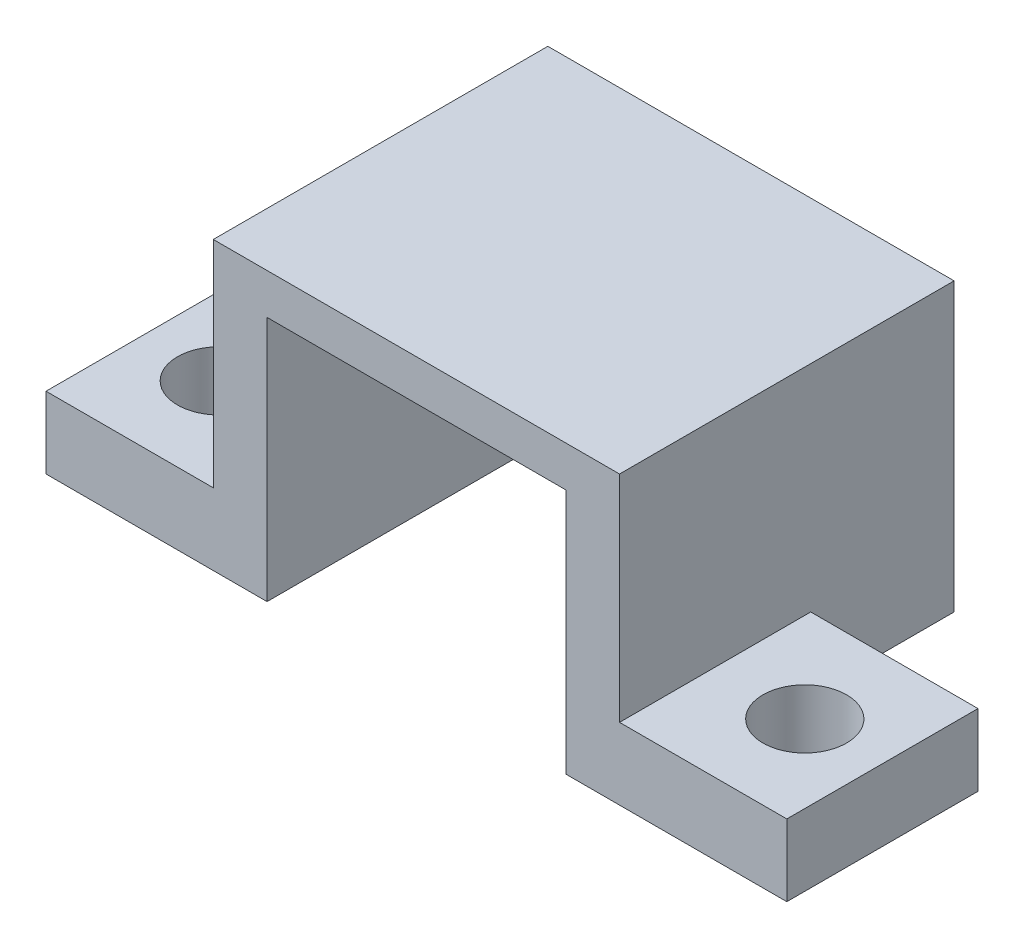
from build123d import *

# Parameters (mm, degrees)
ESBO_O1_W                = 17.000001856
ESBO_O1_H                = 13.999999967
RESSALTO_EXTRUS_O1_DEPTH = 12.000000396
ESBO_O2_W                = 12.500001117
ESBO_O2_H                = 10.30000049
CORTE_EXTRUS_O1_DEPTH    = 14.999999966
ESBO_O3_W                = 7.999999915
ESBO_O3_H                = 3.000000085
RESSALTO_EXTRUS_O2_DEPTH = 6.999999285
ESBO_O4_R                = 1.75
CORTE_EXTRUS_O2_DEPTH    = 13.000000396
ESBO_O5_W                = 7.999999915
ESBO_O5_H                = 3.000000085
RESSALTO_EXTRUS_O3_DEPTH = 6.999999285
ESBO_O6_R                = 1.75
CORTE_EXTRUS_O3_DEPTH    = 13.000000396


with BuildPart() as part:
    # Esboço1 → Ressalto-extrusão1 (new body)
    with BuildSketch(Plane.XZ.offset(-5e-05)):
        with Locations((15.500025358, 7.000024663)):
            Rectangle(ESBO_O1_W, ESBO_O1_H)
    extrude(amount=-RESSALTO_EXTRUS_O1_DEPTH)

    # Esboço2 → Corte-extrusão1 (cut, through all)
    with BuildSketch(Plane.XY.offset(14.000024647)):
        with Locations((15.500024893, 5.150050245)):
            Rectangle(ESBO_O2_W, ESBO_O2_H)
    extrude(amount=-CORTE_EXTRUS_O1_DEPTH, mode=Mode.SUBTRACT)

    # Esboço3 → Ressalto-extrusão2 (add)
    with BuildSketch(Plane.ZY.offset(-7.00002443)):
        with Locations((10.00002469, 1.500050043)):
            Rectangle(ESBO_O3_W, ESBO_O3_H)
    extrude(amount=RESSALTO_EXTRUS_O2_DEPTH)

    # Esboço4 → Corte-extrusão2 (cut, through all)
    with BuildSketch(Plane.XZ.offset(-5e-05)):
        with Locations((3.250025213, 10.000025168)):
            Circle(ESBO_O4_R)
    extrude(amount=-CORTE_EXTRUS_O2_DEPTH, mode=Mode.SUBTRACT)

    # Esboço5 → Ressalto-extrusão3 (add)
    with BuildSketch(Plane(origin=(24.000026286, 0, 0), x_dir=(0, 0, -1), z_dir=(1, 0, 0))):
        with Locations((-10.00002469, 1.500050043)):
            Rectangle(ESBO_O5_W, ESBO_O5_H)
    extrude(amount=RESSALTO_EXTRUS_O3_DEPTH)

    # Esboço6 → Corte-extrusão3 (cut, through all)
    with BuildSketch(Plane.XZ.offset(-5e-05)):
        with Locations((27.751375675, 10.000025168)):
            Circle(ESBO_O6_R)
    extrude(amount=-CORTE_EXTRUS_O3_DEPTH, mode=Mode.SUBTRACT)


solid = part.part
